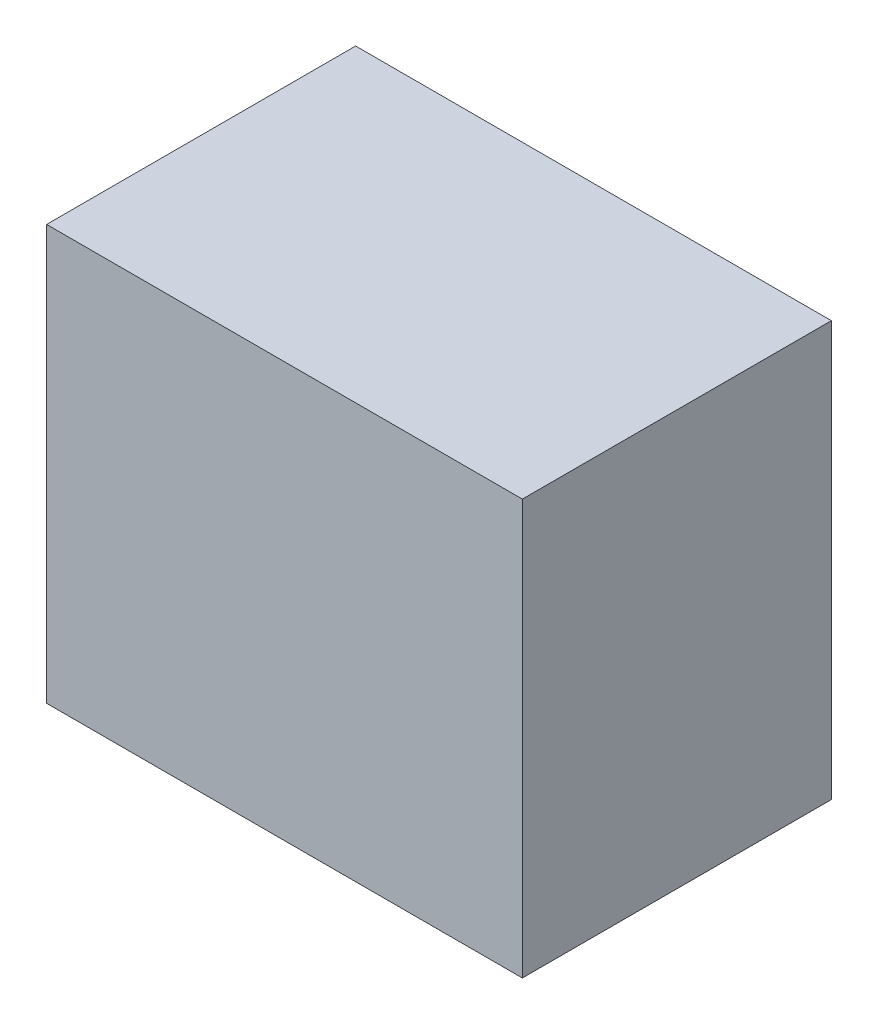
from build123d import *

# Parameters (mm, degrees)
SKETCH1_W           = 11.7
SKETCH1_H           = 7.6
BOSS_EXTRUDE1_DEPTH = 10.2


with BuildPart() as part:
    # Sketch1 → Boss-Extrude1 (new body)
    with BuildSketch(Plane(origin=(0, 0, 0), x_dir=(1, 0, 0), z_dir=(0, 1, 0))):
        with Locations((5.85, 3.8)):
            Rectangle(SKETCH1_W, SKETCH1_H)
    extrude(amount=BOSS_EXTRUDE1_DEPTH)


solid = part.part
